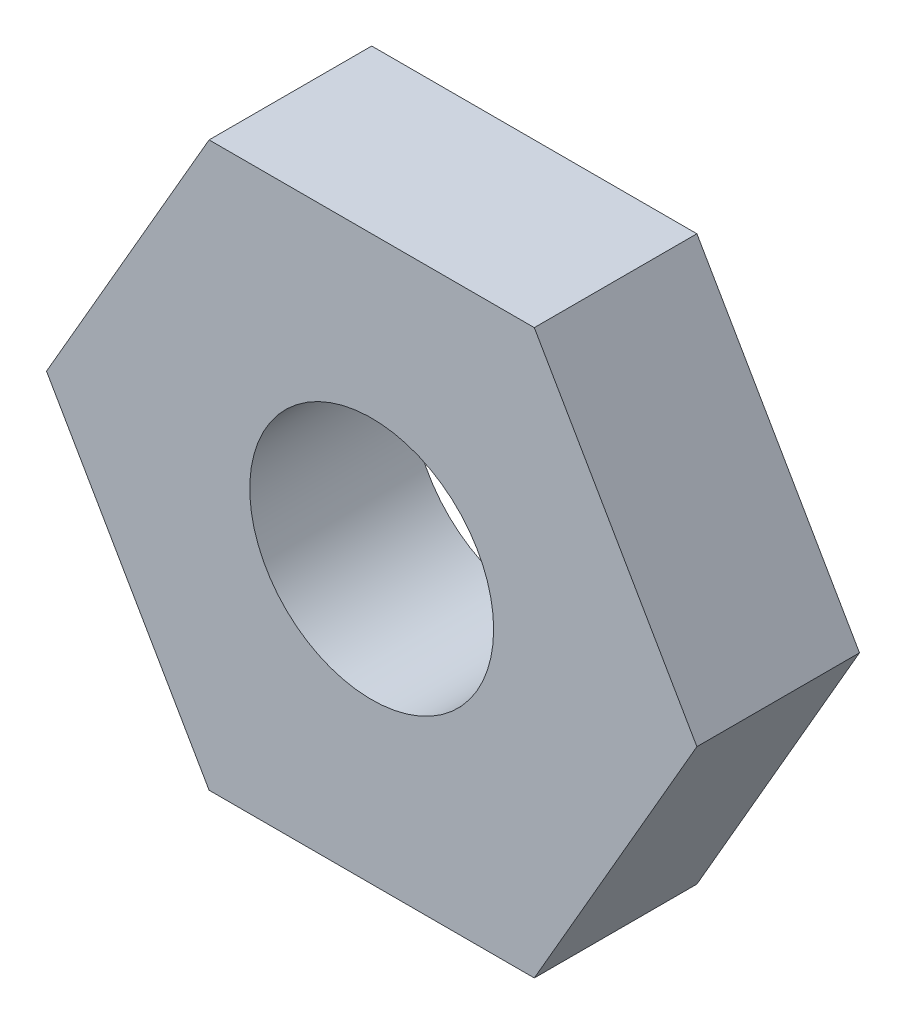
from build123d import *

# Parameters (mm, degrees)
ESQUISSE1_R        = 1.5
BOSS_EXTRU_1_DEPTH = 2


with BuildPart() as part:
    # Esquisse1 → Boss.-Extru.1 (new body)
    with BuildSketch(Plane.XY):
        Polygon((-4, 0), (-2, 3.464101615), (2, 3.464101615), (4, 0), (1.999999923, -3.464101748), (-2.00000023, -3.464101748), align=None)
        Circle(ESQUISSE1_R, mode=Mode.SUBTRACT)
    extrude(amount=BOSS_EXTRU_1_DEPTH)


solid = part.part
